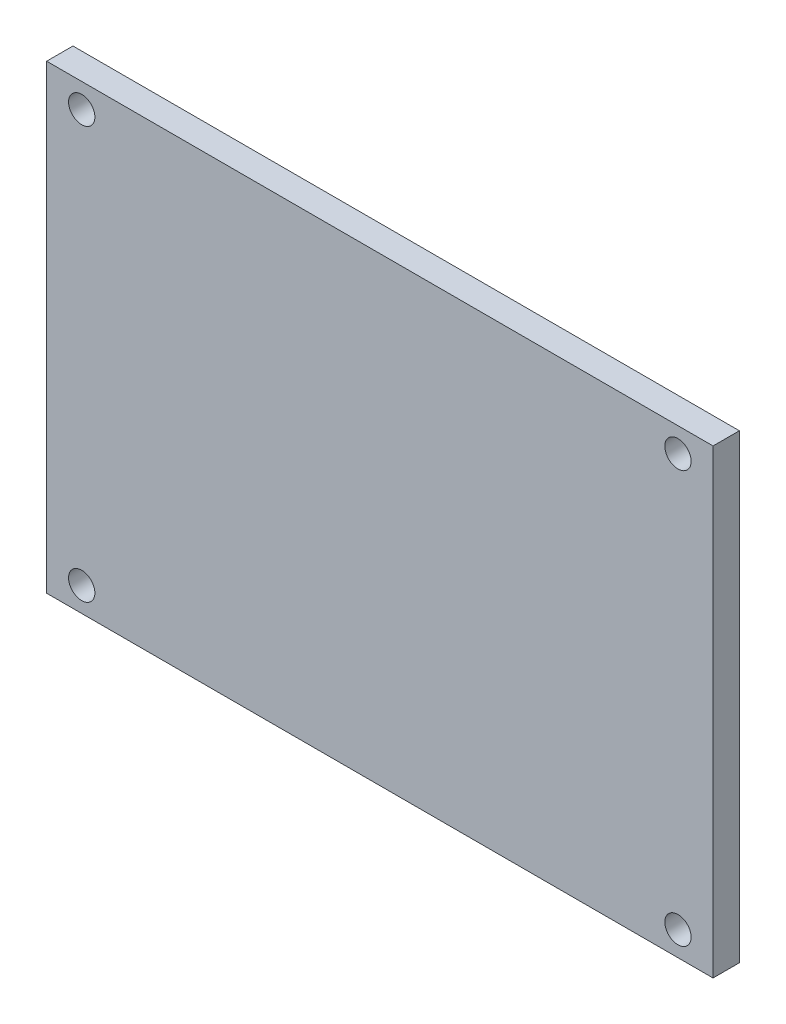
from build123d import *

# Parameters (mm, degrees)
SKETCH1_W           = 76
SKETCH1_H           = 52.55
BOSS_EXTRUDE1_DEPTH = 3
SKETCH2_R           = 1.5
CUT_EXTRUDE1_DEPTH  = 4


with BuildPart() as part:
    # Sketch1 → Boss-Extrude1 (new body)
    with BuildSketch(Plane.XY):
        with Locations((38, 26.275)):
            Rectangle(SKETCH1_W, SKETCH1_H)
    extrude(amount=BOSS_EXTRUDE1_DEPTH)

    # Sketch2 → Cut-Extrude1 (cut, through all)
    with BuildSketch(Plane.XY.offset(3)):
        with Locations((4, 49.775)):
            Circle(SKETCH2_R)
        with Locations((72, 49.775)):
            Circle(SKETCH2_R)
        with Locations((72, 2.775)):
            Circle(SKETCH2_R)
        with Locations((4, 2.775)):
            Circle(SKETCH2_R)
    extrude(amount=-CUT_EXTRUDE1_DEPTH, mode=Mode.SUBTRACT)


solid = part.part
